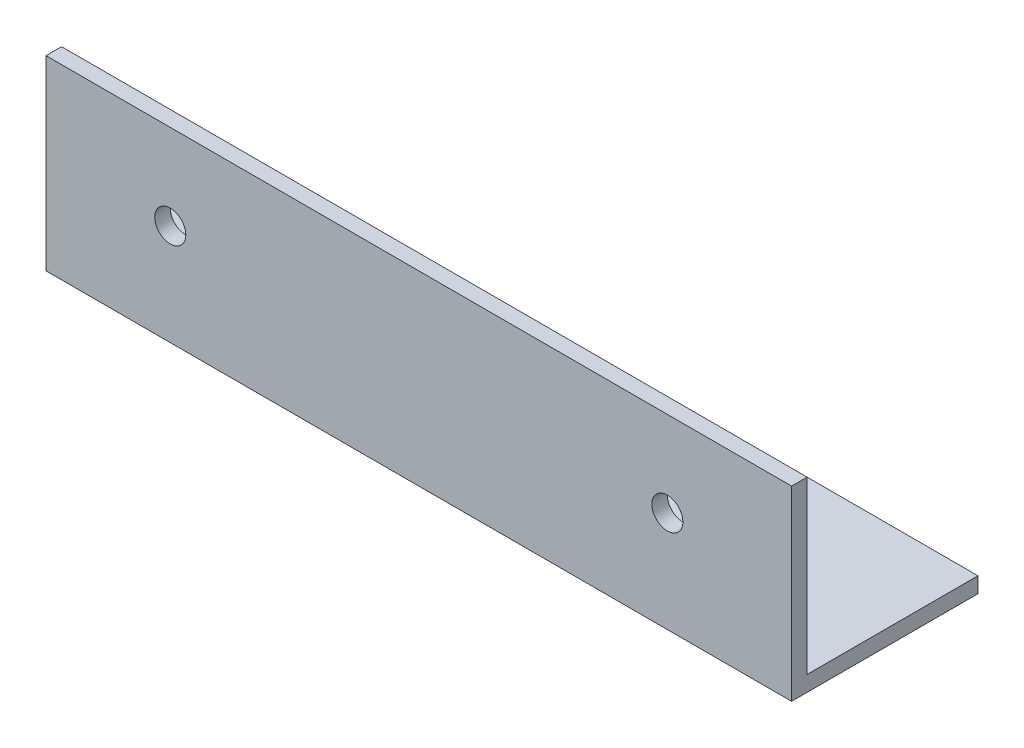
from build123d import *

# Parameters (mm, degrees)
BOSS_EXTRUDE1_DEPTH = 152.4
SKETCH5_R           = 3.175
CUT_EXTRUDE3_DEPTH  = 4.175
SKETCH6_R           = 3.175
CUT_EXTRUDE4_DEPTH  = 4.175


with BuildPart() as part:
    # Sketch1 → Boss-Extrude1 (new body)
    with BuildSketch(Plane(origin=(0, 0, 0), x_dir=(0, 0, -1), z_dir=(1, 0, 0))):
        Polygon((0, 0), (0, 38.1), (3.175, 38.1), (3.175, 3.175), (38.1, 3.175), (38.1, 0), align=None)
    extrude(amount=BOSS_EXTRUDE1_DEPTH)

    # Sketch5 → Cut-Extrude3 (cut, through all)
    with BuildSketch(Plane(origin=(0, 0, -3.175), x_dir=(-1, 0, 0), z_dir=(0, 0, -1))):
        with Locations((-127, 20.6375)):
            Circle(SKETCH5_R)
        with Locations((-25.4, 20.6375)):
            Circle(SKETCH5_R)
    extrude(amount=-CUT_EXTRUDE3_DEPTH, mode=Mode.SUBTRACT)

    # Sketch6 → Cut-Extrude4 (cut, through all)
    with BuildSketch(Plane(origin=(0, 3.175, 0), x_dir=(1, 0, 0), z_dir=(0, 1, 0))):
        with Locations((25.4, 20.6375)):
            Circle(SKETCH6_R)
        with Locations((127, 20.6375)):
            Circle(SKETCH6_R)
    extrude(amount=-CUT_EXTRUDE4_DEPTH, mode=Mode.SUBTRACT)


solid = part.part
